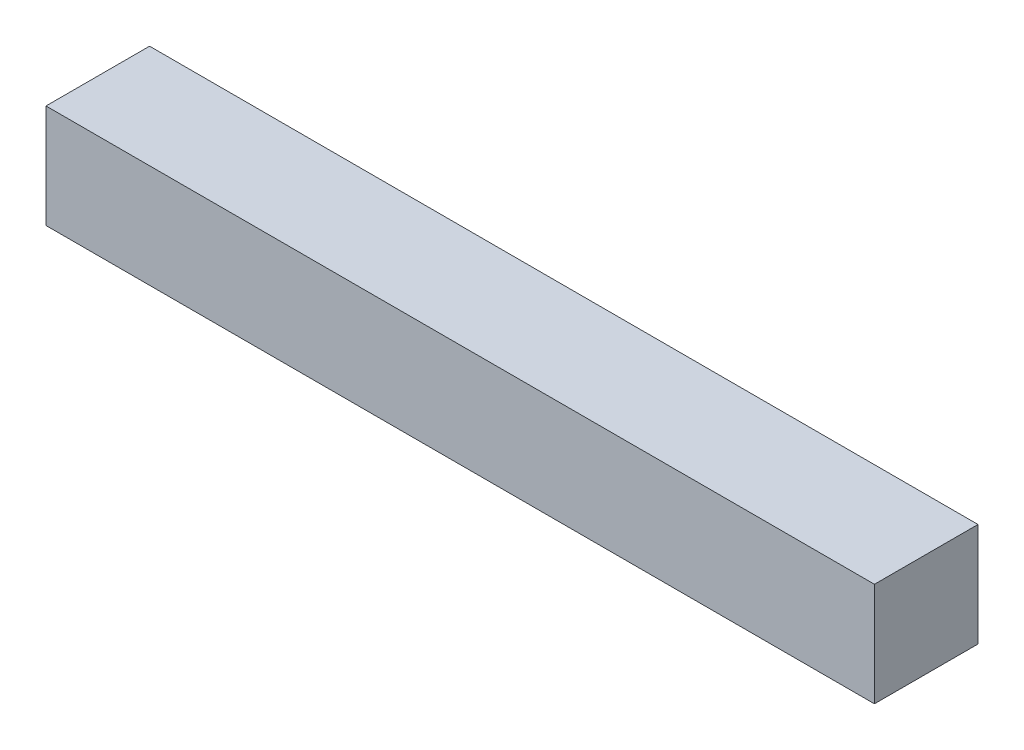
from build123d import *

# Parameters (mm, degrees)
SKETCH1_W      = 25.4
SKETCH1_H      = 3.175
EXTRUDE1_DEPTH = 3.175


with BuildPart() as part:
    # Sketch1 → Extrude1 (new body)
    with BuildSketch(Plane(origin=(0, 0, 0), x_dir=(1, 0, 0), z_dir=(0, 1, 0))):
        Rectangle(SKETCH1_W, SKETCH1_H)
    extrude(amount=-EXTRUDE1_DEPTH)


solid = part.part
